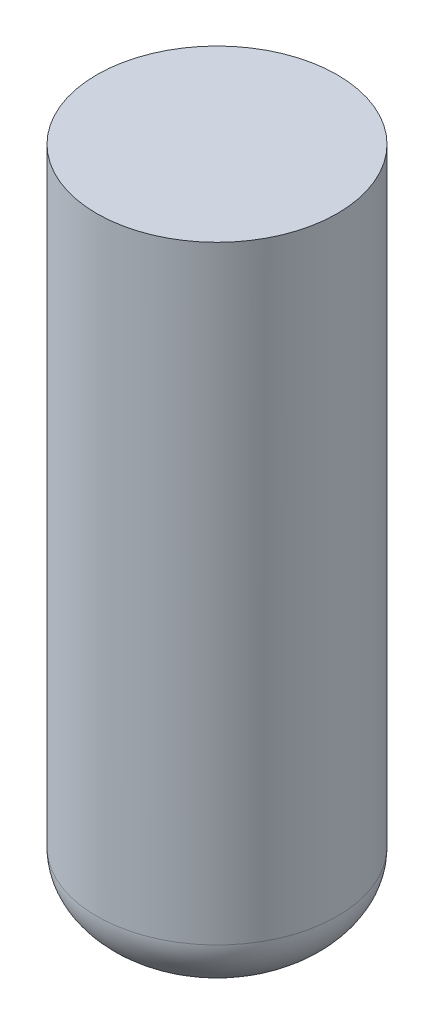
from build123d import *

# Parameters (mm, degrees)
SKETCH1_R                = 95.25
BOSS_EXTRUDE1_DEPTH      = 482.6
SKETCH4_R                = 95.25
F_7_PERCENT_ULLAGE_DEPTH = 62.484


with BuildPart() as part:
    # Sketch1 → Boss-Extrude1 (new body)
    with BuildSketch(Plane(origin=(0, 0, 0), x_dir=(1, 0, 0), z_dir=(0, 1, 0))):
        Circle(SKETCH1_R)
    extrude(amount=BOSS_EXTRUDE1_DEPTH)

    # Sketch2 → Revolve1 (revolve)
    with BuildSketch(Plane(origin=(0, 0, 0), x_dir=(0, 0, -1), z_dir=(1, 0, 0))):
        with BuildLine():
            Line((0, 544.576), (0, 482.6))
            Line((0, 482.6), (95.25, 482.6))
            add(Edge.make_bspline(
                [(95.25, 482.6), (95.25, 544.576), (0, 544.576)],
                knots=[0, 0, 0, 1.570796327, 1.570796327, 1.570796327], degree=2, weights=[1, 0.707106781, 1]))
        make_face()
    revolve(axis=Axis((0, 544.576, 0), (0, -1, 0)))

    # Sketch3 → Revolve2 (revolve)
    with BuildSketch(Plane(origin=(0, 0, 0), x_dir=(0, 0, -1), z_dir=(1, 0, 0))):
        with BuildLine():
            Line((0, -59.69), (0, 0))
            Line((0, 0), (95.25, 0))
            add(Edge.make_bspline(
                [(0, -59.69), (95.25, -59.69), (95.25, 0)],
                knots=[4.71238898, 4.71238898, 4.71238898, 6.283185307, 6.283185307, 6.283185307], degree=2, weights=[1, 0.707106781, 1]))
        make_face()
    revolve(axis=Axis((0, -59.69, 0), (0, 1, 0)))

    # Sketch4 → 7 Percent Ullage (cut)
    with BuildSketch(Plane(origin=(0, 544.576, 0), x_dir=(1, 0, 0), z_dir=(0, 1, 0))):
        Circle(SKETCH4_R)
    extrude(amount=-F_7_PERCENT_ULLAGE_DEPTH, mode=Mode.SUBTRACT)


solid = part.part
